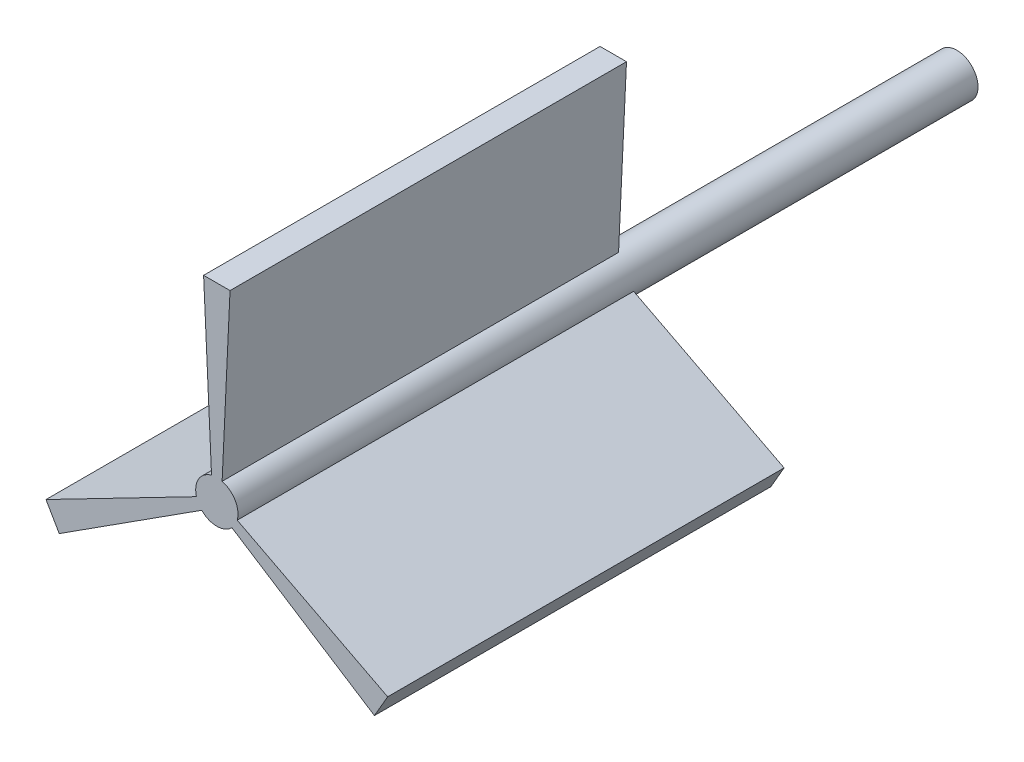
from build123d import *

# Parameters (mm, degrees)
SKETCH1_R           = 4
BOSS_EXTRUDE1_DEPTH = 140
BOSS_EXTRUDE2_DEPTH = 75


with BuildPart() as part:
    # Sketch1 → Boss-Extrude1 (new body)
    with BuildSketch(Plane.XY):
        Circle(SKETCH1_R)
    extrude(amount=BOSS_EXTRUDE1_DEPTH)

    # Sketch2 → Boss-Extrude2 (add)
    with BuildSketch(Plane.XY.offset(140)):
        Polygon((2.5, 35.872983346), (-2.5, 35.872983346), (-1, 3.872983346), (1, 3.872983346), align=None)
        Polygon((32.316914887, -15.771428164), (3.854101966, -1.070466269), (2.854101966, -2.802517077), (29.816914887, -20.101555183), align=None)
        Polygon((-29.816914887, -20.101555183), (-2.854101966, -2.802517077), (-3.854101966, -1.070466269), (-32.316914887, -15.771428164), align=None)
    extrude(amount=-BOSS_EXTRUDE2_DEPTH)


solid = part.part
